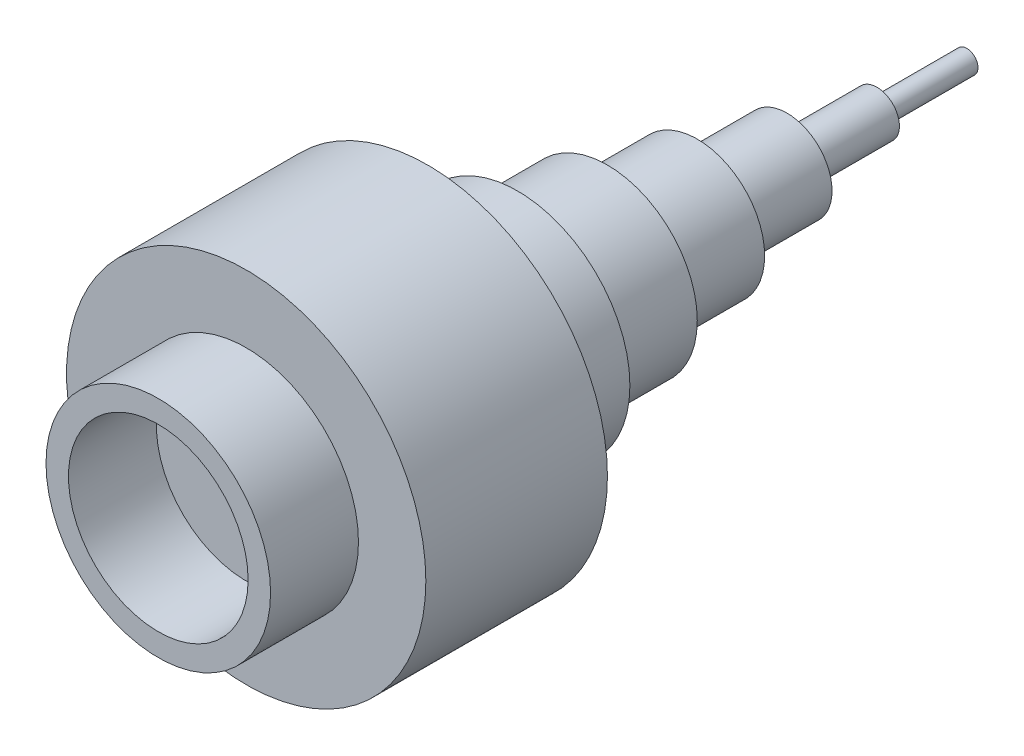
from build123d import *


with BuildPart() as part:
    # Sketch1 → Revolve1 (revolve)
    with BuildSketch(Plane(origin=(0, 0, 0), x_dir=(1, 0, 0), z_dir=(0, 1, 0))):
        Polygon((0, 180), (2.5, 180), (2.5, 160), (5, 160), (5, 140), (10, 140), (10, 120), (15, 120), (15, 100), (20, 100), (20, 80), (25, 80), (25, 60), (40, 60), (40, 19.569895176), (25, 19.569895176), (25, 0), (20, 0), (20, 19.569895176), (0, 19.569895176), align=None)
    revolve(axis=Axis((0, 0, 0), (0, 0, -1)))


solid = part.part
